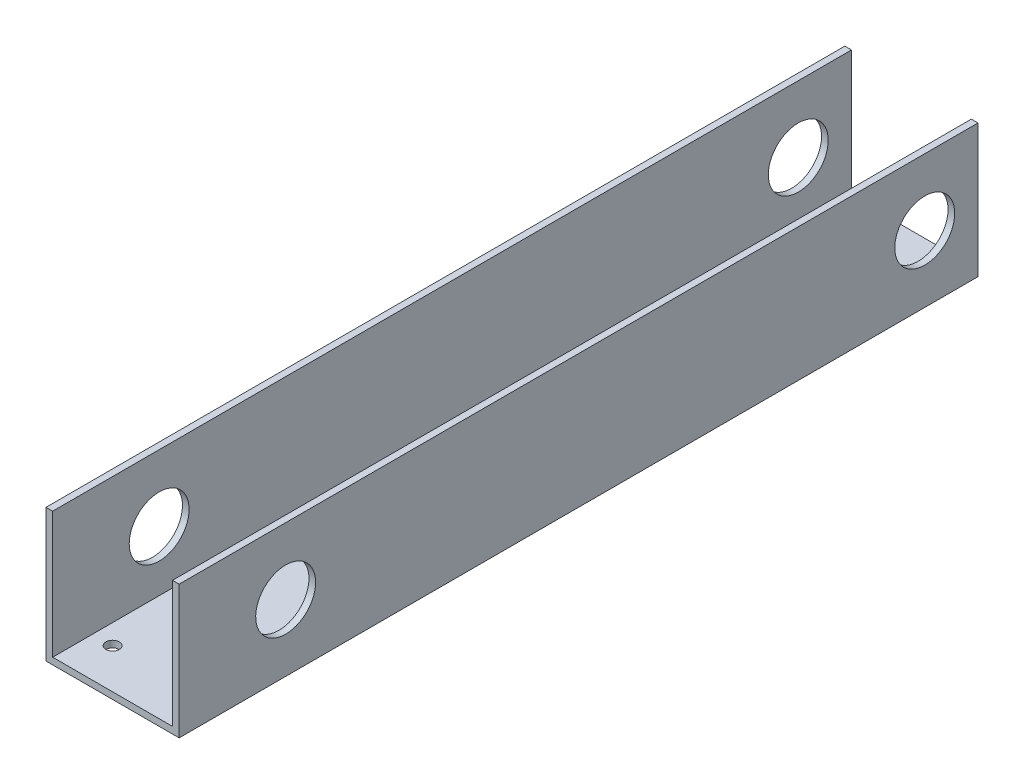
from build123d import *

# Parameters (mm, degrees)
BOSS_EXTRUDE1_DEPTH     = 381
SKETCH2_R               = 3.175
CUT_EXTRUDE1_DEPTH      = 1
CUT_EXTRUDE1_DEPTH_BACK = 64.5
SKETCH3_R               = 14.2875
CUT_EXTRUDE2_DEPTH      = 1
CUT_EXTRUDE2_DEPTH_BACK = 64.5


with BuildPart() as part:
    # Sketch1 → Boss-Extrude1 (new body)
    with BuildSketch(Plane.XY):
        Polygon((0, 0), (63.5, 0), (63.5, 63.5), (60.325, 63.5), (60.325, 3.175), (3.175, 3.175), (3.175, 63.5), (0, 63.5), align=None)
    extrude(amount=BOSS_EXTRUDE1_DEPTH)

    # Sketch2 → Cut-Extrude1 (cut, two sides)
    with BuildSketch(Plane.XZ) as cut_extrude1_sk:
        with Locations((12.7, 361.95)):
            Circle(SKETCH2_R)
        with Locations((50.8, 361.95)):
            Circle(SKETCH2_R)
        with Locations((50.8, 285.75)):
            Circle(SKETCH2_R)
        with Locations((50.8, 209.55)):
            Circle(SKETCH2_R)
        with Locations((50.8, 133.35)):
            Circle(SKETCH2_R)
        with Locations((50.8, 57.15)):
            Circle(SKETCH2_R)
    extrude(amount=CUT_EXTRUDE1_DEPTH, mode=Mode.SUBTRACT)
    extrude(cut_extrude1_sk.sketch, amount=-CUT_EXTRUDE1_DEPTH_BACK, mode=Mode.SUBTRACT)

    # Sketch3 → Cut-Extrude2 (cut, two sides)
    with BuildSketch(Plane(origin=(63.5, 0, 0), x_dir=(0, 0, -1), z_dir=(1, 0, 0))) as cut_extrude2_sk:
        with Locations((-25.4, 31.75)):
            Circle(SKETCH3_R)
        with Locations((-330.2, 31.75)):
            Circle(SKETCH3_R)
    extrude(amount=CUT_EXTRUDE2_DEPTH, mode=Mode.SUBTRACT)
    extrude(cut_extrude2_sk.sketch, amount=-CUT_EXTRUDE2_DEPTH_BACK, mode=Mode.SUBTRACT)


solid = part.part
